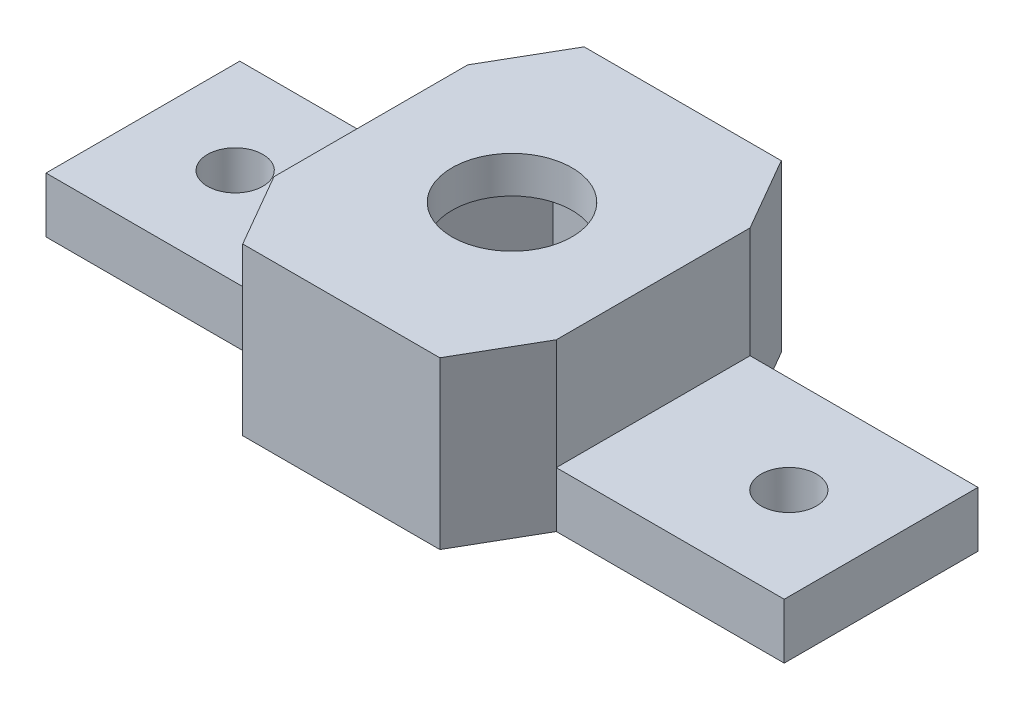
from build123d import *

# Parameters (mm, degrees)
ESQUISSE1_R             = 1.5
BOSS_EXTRU_1_DEPTH      = 7
ENL_V_MAT_EXTRU_1_REACH = 16.5
ESQUISSE2_W             = 12.350108933
ESQUISSE2_H             = 4
ESQUISSE3_R             = 3.25
BOSS_EXTRU_2_DEPTH      = 2


with BuildPart() as part:
    # Esquisse1 → Boss.-Extru.1 (new body)
    with BuildSketch(Plane(origin=(0, 0, 0), x_dir=(1, 0, 0), z_dir=(0, 1, 0))):
        Polygon((5.34048999, 9.25), (-5.34048999, 9.25), (-7.649891067, 5.25), (-20, 5.25), (-20, -5.25), (-7.649891067, -5.25), (-5.34048999, -9.25), (5.34048999, -9.25), (7.649891067, -5.25), (20, -5.25), (20, 5.25), (7.649891067, 5.25), align=None)
        with Locations((-15, 0)):
            Circle(ESQUISSE1_R, mode=Mode.SUBTRACT)
        with Locations((15, 0)):
            Circle(ESQUISSE1_R, mode=Mode.SUBTRACT)
        Polygon((6.062177826, 0), (3.031088913, 5.25), (-3.031088913, 5.25), (-6.062177826, 0), (-3.031088913, -5.25), (3.031088913, -5.25), align=None, mode=Mode.SUBTRACT)
    extrude(amount=BOSS_EXTRU_1_DEPTH)

    # Esquisse2 → Enlèv. mat.-Extru.1 (cut, up to next)
    with BuildSketch(Plane.XY.offset(5.25), mode=Mode.PRIVATE) as enl_v_mat_extru_1_sk1:
        with Locations((-13.824945533, 5)):
            Rectangle(ESQUISSE2_W, ESQUISSE2_H)
    enl_v_mat_extru_1_tool1 = extrude(enl_v_mat_extru_1_sk1.sketch, amount=-ENL_V_MAT_EXTRU_1_REACH, mode=Mode.PRIVATE) & part.part
    add(enl_v_mat_extru_1_tool1.solids().sort_by_distance((-13.824946, 5, 5.25))[0], mode=Mode.SUBTRACT)
    # Esquisse2 → Enlèv. mat.-Extru.1 (cut, up to next)
    with BuildSketch(Plane.XY.offset(5.25), mode=Mode.PRIVATE) as enl_v_mat_extru_1_sk2:
        with Locations((13.824945533, 5)):
            Rectangle(ESQUISSE2_W, ESQUISSE2_H)
    enl_v_mat_extru_1_tool2 = extrude(enl_v_mat_extru_1_sk2.sketch, amount=-ENL_V_MAT_EXTRU_1_REACH, mode=Mode.PRIVATE) & part.part
    add(enl_v_mat_extru_1_tool2.solids().sort_by_distance((13.824946, 5, 5.25))[0], mode=Mode.SUBTRACT)

    # Esquisse3 → Boss.-Extru.2 (add)
    with BuildSketch(Plane(origin=(0, 7, 0), x_dir=(1, 0, 0), z_dir=(0, 1, 0))):
        Polygon((-7.649891067, -5.25), (-7.649891067, 5.25), (-5.34048999, 9.25), (5.34048999, 9.25), (7.649891067, 5.25), (7.649891067, -5.25), (5.34048999, -9.25), (-5.34048999, -9.25), align=None)
        Circle(ESQUISSE3_R, mode=Mode.SUBTRACT)
    extrude(amount=BOSS_EXTRU_2_DEPTH)


solid = part.part
